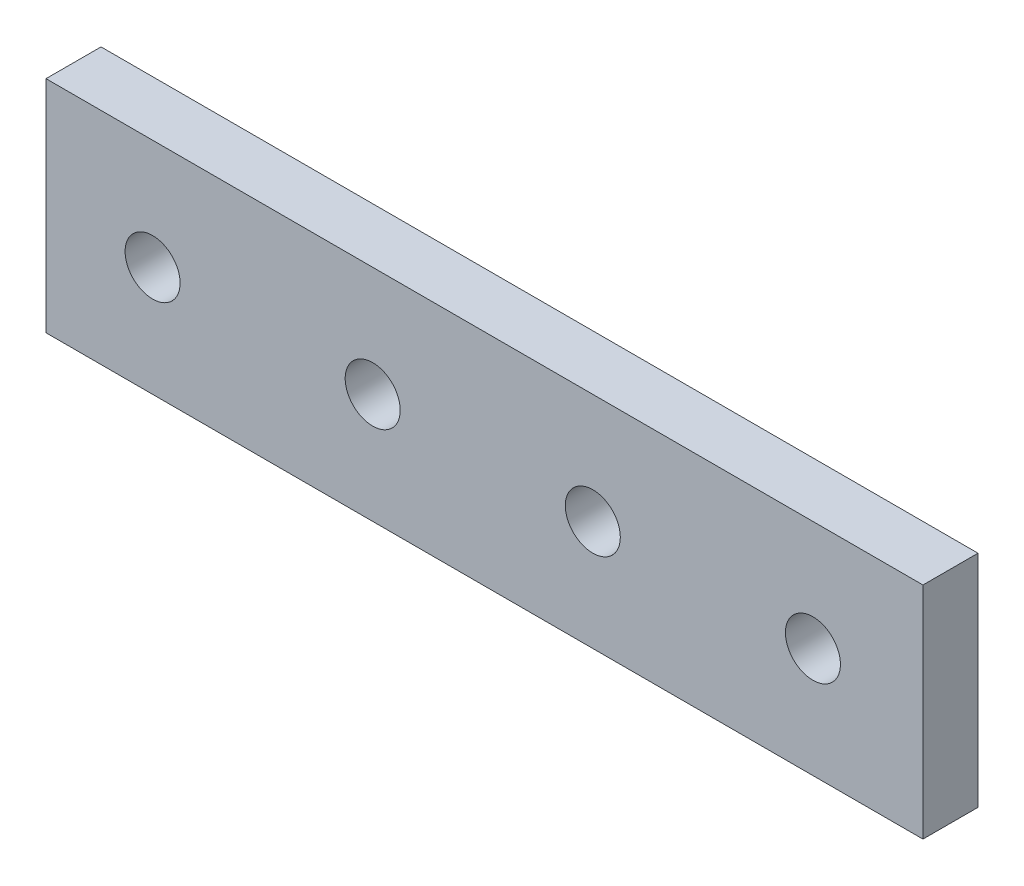
from build123d import *

# Parameters (mm, degrees)
SKETCH1_W           = 101.2
SKETCH1_H           = 25.4
BOSS_EXTRUDE1_DEPTH = 6.35
SKETCH2_R           = 3.175
CUT_EXTRUDE1_DEPTH  = 6.35


with BuildPart() as part:
    # Sketch1 → Boss-Extrude1 (new body)
    with BuildSketch(Plane.XY):
        Rectangle(SKETCH1_W, SKETCH1_H)
    extrude(amount=BOSS_EXTRUDE1_DEPTH)

    # Sketch2 → Cut-Extrude1 (cut)
    with BuildSketch(Plane.XY.offset(6.35)):
        with Locations((-38.3, 0)):
            Circle(SKETCH2_R)
        with Locations((12.5, 0)):
            Circle(SKETCH2_R)
        with Locations((37.9, 0)):
            Circle(SKETCH2_R)
        with Locations((-12.9, 0)):
            Circle(SKETCH2_R)
    extrude(amount=-CUT_EXTRUDE1_DEPTH, mode=Mode.SUBTRACT)


solid = part.part
